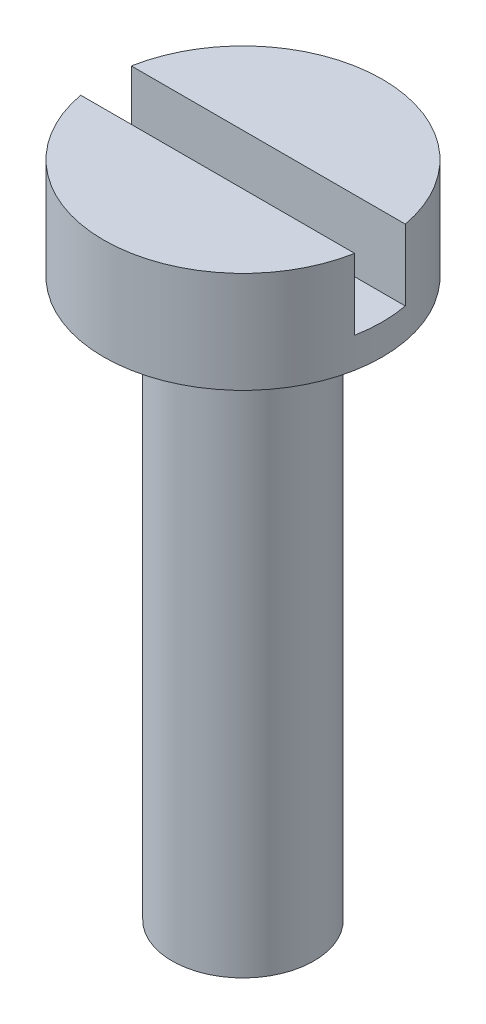
from build123d import *

# Parameters (mm, degrees)
SKETCH1_R               = 2.75
BOSS_EXTRUDE1_DEPTH     = 2
SKETCH2_R               = 1.4
BOSS_EXTRUDE2_DEPTH     = 11
SKETCH3_W               = 1
SKETCH3_H               = 1.4
CUT_EXTRUDE1_DEPTH      = 3.75
CUT_EXTRUDE1_DEPTH_BACK = 3.75


with BuildPart() as part:
    # Sketch1 → Boss-Extrude1 (new body)
    with BuildSketch(Plane(origin=(0, 0, 0), x_dir=(1, 0, 0), z_dir=(0, 1, 0))):
        Circle(SKETCH1_R)
    extrude(amount=BOSS_EXTRUDE1_DEPTH)

    # Sketch2 → Boss-Extrude2 (add)
    with BuildSketch(Plane.XZ):
        Circle(SKETCH2_R)
    extrude(amount=BOSS_EXTRUDE2_DEPTH)

    # Sketch3 → Cut-Extrude1 (cut, two sides)
    with BuildSketch(Plane(origin=(0, 0, 0), x_dir=(0, 0, -1), z_dir=(1, 0, 0))) as cut_extrude1_sk:
        with Locations((0, 1.3)):
            Rectangle(SKETCH3_W, SKETCH3_H)
    extrude(amount=CUT_EXTRUDE1_DEPTH, mode=Mode.SUBTRACT)
    extrude(cut_extrude1_sk.sketch, amount=-CUT_EXTRUDE1_DEPTH_BACK, mode=Mode.SUBTRACT)


solid = part.part
